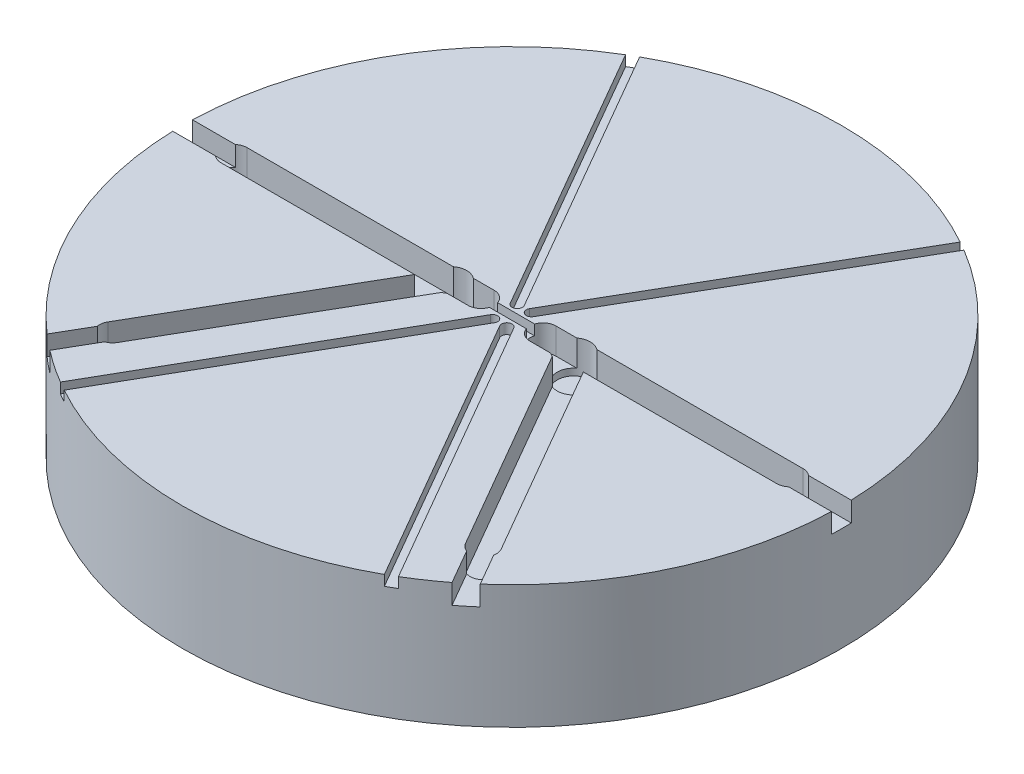
from build123d import *

# Parameters (mm, degrees)
SKETCH1_R           = 8
BOSS_EXTRUDE1_DEPTH = 3
CUT_EXTRUDE1_DEPTH  = 0.25
SKETCH3_R           = 0.4
CUT_EXTRUDE2_DEPTH  = 0.8
CUT_EXTRUDE4_DEPTH  = 0.635
CUT_EXTRUDE6_DEPTH  = 0.48


with BuildPart() as part:
    # Sketch1 → Boss-Extrude1 (new body)
    with BuildSketch(Plane(origin=(0, 0, 0), x_dir=(1, 0, 0), z_dir=(0, 1, 0))):
        Circle(SKETCH1_R)
    extrude(amount=-BOSS_EXTRUDE1_DEPTH)

    # Sketch2 → Cut-Extrude1 (cut)
    with BuildSketch(Plane(origin=(0, 0, 0), x_dir=(1, 0, 0), z_dir=(0, 1, 0))):
        with BuildLine():
            Line((-0.75, 0.1), (0.75, 0.1))
            ThreePointArc((0.75, 0.1), (0.85, 0), (0.75, -0.1))
            Line((0.75, -0.1), (-0.75, -0.1))
            ThreePointArc((-0.75, -0.1), (-0.85, 0), (-0.75, 0.1))
        make_face()
        with BuildLine():
            Line((0.064947675, 0.362501474), (4.891747675, 8.722501474))
            ThreePointArc((4.891747675, 8.722501474), (5.062501474, 8.768252325), (5.108252325, 8.597498526))
            Line((5.108252325, 8.597498526), (0.281452325, 0.237498526))
            ThreePointArc((0.281452325, 0.237498526), (0.110698526, 0.191747675), (0.064947675, 0.362501474))
        make_face()
        with BuildLine():
            Line((0.281452325, -0.237498526), (5.108252325, -8.597498526))
            ThreePointArc((5.108252325, -8.597498526), (5.062501474, -8.768252325), (4.891747675, -8.722501474))
            Line((4.891747675, -8.722501474), (0.064947675, -0.362501474))
            ThreePointArc((0.064947675, -0.362501474), (0.110698526, -0.191747675), (0.281452325, -0.237498526))
        make_face()
        with BuildLine():
            Line((-0.064747026, -0.362152654), (-4.891547026, -8.784654127))
            ThreePointArc((-4.891547026, -8.784654127), (-5.062152654, -8.830954448), (-5.108452974, -8.66034882))
            Line((-5.108452974, -8.66034882), (-0.281652974, -0.237847346))
            ThreePointArc((-0.281652974, -0.237847346), (-0.111047346, -0.191547026), (-0.064747026, -0.362152654))
        make_face()
        with BuildLine():
            Line((-0.281452325, 0.237498526), (-5.108252325, 8.597498526))
            ThreePointArc((-5.108252325, 8.597498526), (-5.062501474, 8.768252325), (-4.891747675, 8.722501474))
            Line((-4.891747675, 8.722501474), (-0.064947675, 0.362501474))
            ThreePointArc((-0.064947675, 0.362501474), (-0.110698526, 0.191747675), (-0.281452325, 0.237498526))
        make_face()
    extrude(amount=-CUT_EXTRUDE1_DEPTH, mode=Mode.SUBTRACT)

    # Sketch3 → Cut-Extrude2 (cut)
    with BuildSketch(Plane(origin=(0, 0, 0), x_dir=(1, 0, 0), z_dir=(0, 1, 0))):
        with Locations((1.5, 0)):
            Circle(SKETCH3_R)
        with Locations((-1.5, 0)):
            Circle(SKETCH3_R)
    extrude(amount=-CUT_EXTRUDE2_DEPTH, mode=Mode.SUBTRACT)

    # Sketch4 → Cut-Extrude4 (cut)
    with BuildSketch(Plane(origin=(0, 0, 0), x_dir=(1, 0, 0), z_dir=(0, 1, 0))):
        with BuildLine():
            Line((-0.75, -0.3175), (-6.75, -0.3175))
            ThreePointArc((-6.75, -0.3175), (-7.0675, 0), (-6.75, 0.3175))
            Line((-6.75, 0.3175), (-0.75, 0.3175))
            ThreePointArc((-0.75, 0.3175), (-0.4325, 0), (-0.75, -0.3175))
        make_face()
        with BuildLine():
            Line((0.75, 0.3175), (6.75, 0.3175))
            ThreePointArc((6.75, 0.3175), (7.0675, 0), (6.75, -0.3175))
            Line((6.75, -0.3175), (0.75, -0.3175))
            ThreePointArc((0.75, -0.3175), (0.4325, 0), (0.75, 0.3175))
        make_face()
        with BuildLine():
            Line((-1.225038951, -0.158753493), (-4.225104953, -5.354867808))
            ThreePointArc((-4.225104953, -5.354867808), (-4.658819495, -5.471075365), (-4.775027051, -5.037360823))
            Line((-4.775027051, -5.037360823), (-1.774961049, 0.158753493))
            ThreePointArc((-1.774961049, 0.158753493), (-1.341246507, 0.274961049), (-1.225038951, -0.158753493))
        make_face()
        with BuildLine():
            Line((1.774961049, 0.158753493), (4.775027051, -5.037360823))
            ThreePointArc((4.775027051, -5.037360823), (4.658819495, -5.471075365), (4.225104953, -5.354867808))
            Line((4.225104953, -5.354867808), (1.225038951, -0.158753493))
            ThreePointArc((1.225038951, -0.158753493), (1.341246507, 0.274961049), (1.774961049, 0.158753493))
        make_face()
    extrude(amount=-CUT_EXTRUDE4_DEPTH, mode=Mode.SUBTRACT)

    # Sketch5 → Cut-Extrude6 (cut)
    with BuildSketch(Plane(origin=(0, 0, 0), x_dir=(1, 0, 0), z_dir=(0, 1, 0))):
        with BuildLine():
            Line((-6.75, -0.24), (-8.75, -0.24))
            ThreePointArc((-8.75, -0.24), (-8.99, 0), (-8.75, 0.24))
            Line((-8.75, 0.24), (-6.75, 0.24))
            ThreePointArc((-6.75, 0.24), (-6.51, 0), (-6.75, -0.24))
        make_face()
        with BuildLine():
            Line((6.75, 0.24), (8.75, 0.24))
            ThreePointArc((8.75, 0.24), (8.99, 0), (8.75, -0.24))
            Line((8.75, -0.24), (6.75, -0.24))
            ThreePointArc((6.75, -0.24), (6.51, 0), (6.75, 0.24))
        make_face()
        with BuildLine():
            Line((-4.29222143, -5.316116956), (-6.844144056, -9.736046945))
            ThreePointArc((-6.844144056, -9.736046945), (-7.171991269, -9.823888878), (-7.259833201, -9.496041665))
            Line((-7.259833201, -9.496041665), (-4.707910575, -5.076111676))
            ThreePointArc((-4.707910575, -5.076111676), (-4.380063362, -4.988269743), (-4.29222143, -5.316116956))
        make_face()
        with BuildLine():
            Line((4.707910575, -5.076111676), (7.190547612, -9.376039025))
            ThreePointArc((7.190547612, -9.376039025), (7.10270568, -9.703886238), (6.774858467, -9.616044305))
            Line((6.774858467, -9.616044305), (4.29222143, -5.316116956))
            ThreePointArc((4.29222143, -5.316116956), (4.380063362, -4.988269743), (4.707910575, -5.076111676))
        make_face()
    extrude(amount=-CUT_EXTRUDE6_DEPTH, mode=Mode.SUBTRACT)


solid = part.part
